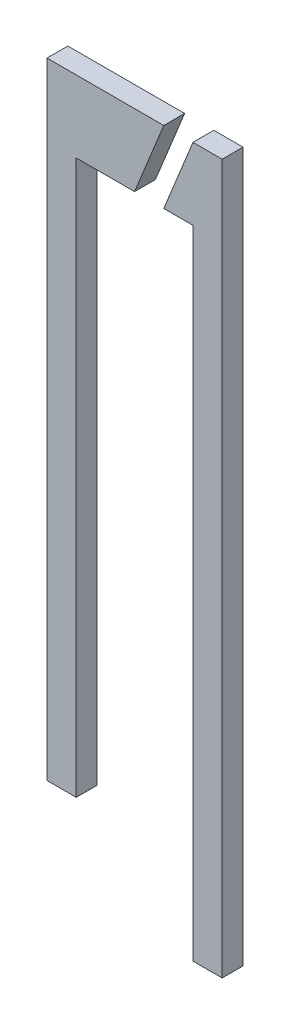
from build123d import *

# Parameters (mm, degrees)
EXTRUDE2_DEPTH   = 0.5
EXTRUDE2_2_DEPTH = 0.5


with BuildPart() as part:
    # Sketch2 → Extrude2 (new body)
    with BuildSketch(Plane.XY):
        Polygon((2.1, -1.724992027), (2.1, 15.275007973), (1.4, 15.275007973), (0.7, 13.551244435), (1.4, 13.551244435), (1.4, -1.724992027), align=None)
    extrude(amount=EXTRUDE2_DEPTH)


with BuildPart() as body_2:
    # Sketch2 → Extrude2 2 (new body)
    with BuildSketch(Plane.XY):
        Polygon((0.7, 15.275007973), (0, 13.551244435), (-1.4, 13.551244435), (-1.4, 0.275007973), (-2.1, 0.275007973), (-2.1, 15.275007973), align=None)
    extrude(amount=EXTRUDE2_2_DEPTH)


solid = Compound([part.part, body_2.part])
